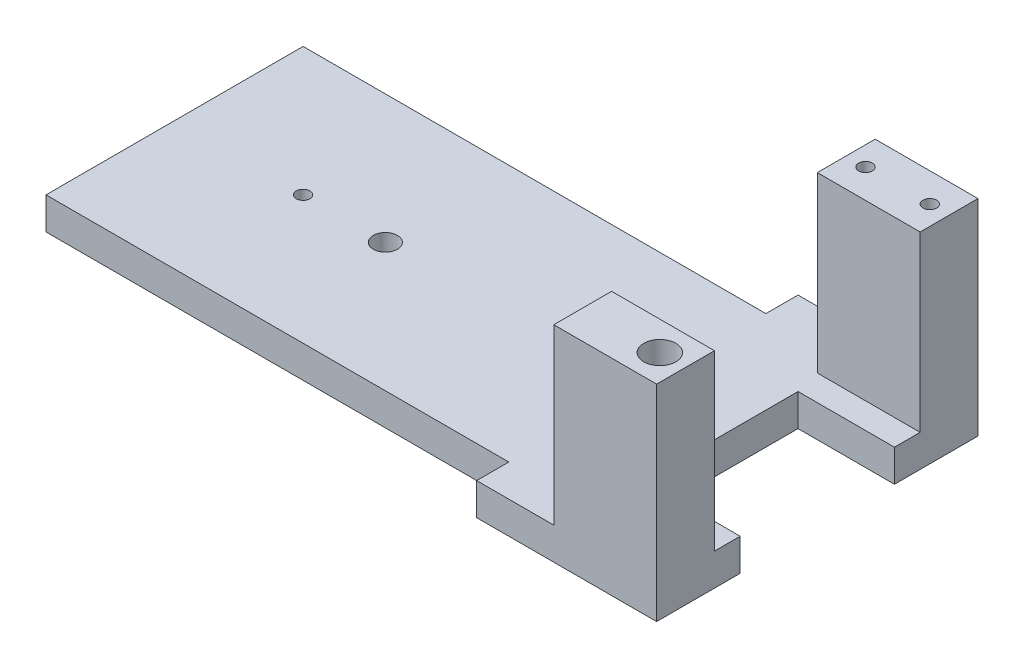
from build123d import *

# Parameters (mm, degrees)
BOSS_EXTRUDE3_DEPTH          = 6.35
SKETCH4_W                    = 20.32
SKETCH4_H                    = 11.43
BOSS_EXTRUDE4_DEPTH          = 34.29
SKETCH5_W                    = 19.05
SKETCH5_H                    = 30.48
CUT_EXTRUDE1_DEPTH           = 12.7
F_3_16_0_1875_DOWEL_HOLE4_D  = 4.7625
F_1_4_0_2500_DOWEL_HOLE1_D   = 6.35
F_36_0_1065_DIAMETER_HOLE1_D = 2.7051
F_6_32_TAPPED_HOLE1_D        = 2.7051


with BuildPart() as part:
    # Sketch2 → Boss-Extrude3 (new body)
    with BuildSketch(Plane(origin=(0, 0, 0), x_dir=(1, 0, 0), z_dir=(0, 1, 0))):
        Polygon((91.44, 6.35), (127, 6.35), (127, 69.85), (91.44, 69.85), (91.44, 63.5), (0, 63.5), (0, 12.7), (91.44, 12.7), align=None)
    extrude(amount=-BOSS_EXTRUDE3_DEPTH)

    # Sketch4 → Boss-Extrude4 (add)
    with BuildSketch(Plane(origin=(0, 0, 0), x_dir=(1, 0, 0), z_dir=(0, 1, 0))):
        with Locations((116.84, 64.135)):
            Rectangle(SKETCH4_W, SKETCH4_H)
        with Locations((116.84, 12.065)):
            Rectangle(SKETCH4_W, SKETCH4_H)
    extrude(amount=BOSS_EXTRUDE4_DEPTH)

    # Sketch5 → Cut-Extrude1 (cut)
    with BuildSketch(Plane(origin=(0, 0, 0), x_dir=(1, 0, 0), z_dir=(0, 1, 0))):
        with Locations((117.475, 38.1)):
            Rectangle(SKETCH5_W, SKETCH5_H)
    extrude(amount=-CUT_EXTRUDE1_DEPTH, mode=Mode.SUBTRACT)

    # 3/16 (0.1875) Dowel Hole4 (through all)
    with Locations(Plane(origin=(0, 0, 0), x_dir=(1, 0, 0), z_dir=(0, 1, 0))):
        with Locations((41.656, 38.1)):
            Hole(F_3_16_0_1875_DOWEL_HOLE4_D / 2)

    # 1/4 (0.2500) Dowel Hole1 (through all)
    with Locations(Plane(origin=(0, 34.29, 0), x_dir=(1, 0, 0), z_dir=(0, 1, 0))):
        with Locations((121.92, 12.065)):
            Hole(F_1_4_0_2500_DOWEL_HOLE1_D / 2)

    # #36 (0.1065) Diameter Hole1 (through all)
    with Locations(Plane(origin=(0, 0, 0), x_dir=(1, 0, 0), z_dir=(0, 1, 0))):
        with Locations((25.4, 38.1), (79.375, 38.1)):
            Hole(F_36_0_1065_DIAMETER_HOLE1_D / 2)

    # #6-32 Tapped Hole1 (through all)
    with Locations(Plane(origin=(0, 34.29, 0), x_dir=(1, 0, 0), z_dir=(0, 1, 0))):
        with Locations((123.19, 64.135), (110.49, 64.135)):
            Hole(F_6_32_TAPPED_HOLE1_D / 2)


solid = part.part
